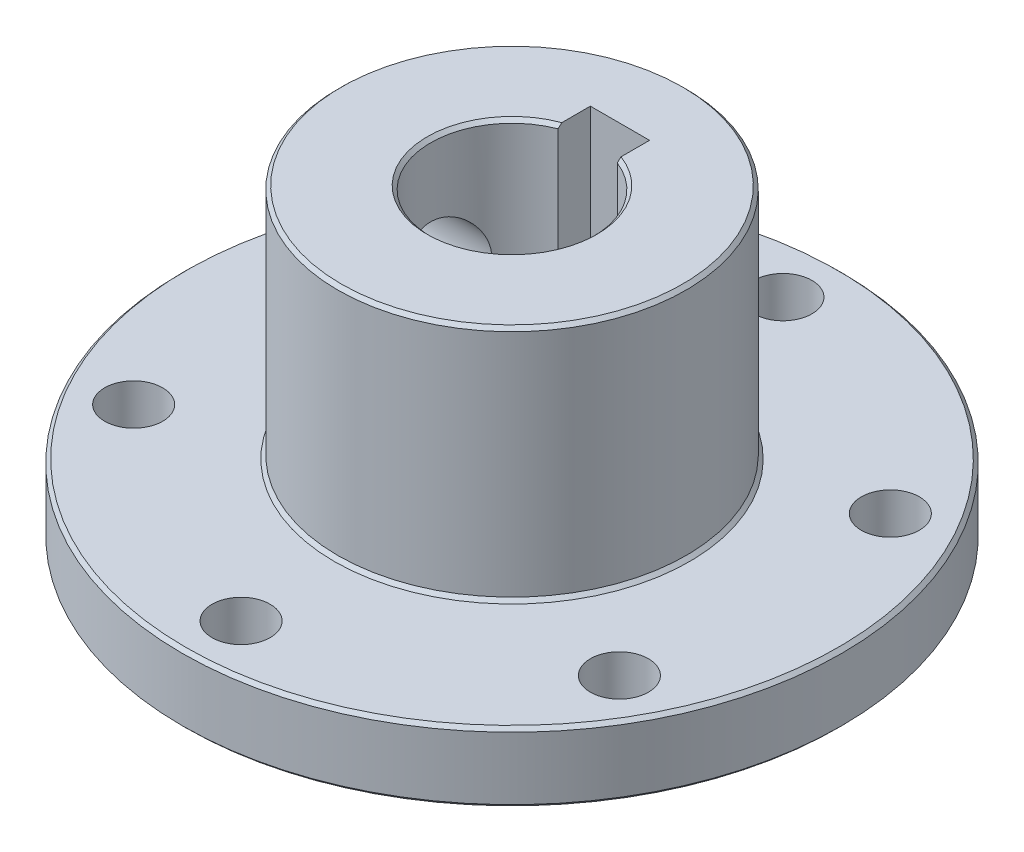
from build123d import *

# Parameters (mm, degrees)
ESQUISSE1_R             = 28.4
ESQUISSE1_R_2           = 7
BOSS_EXTRU_1_DEPTH      = 26.4
ESQUISSE2_OUTSIDE_W     = 75.71
ESQUISSE2_OUTSIDE_H     = 75.71
ESQUISSE2_OUTSIDE_R     = 15
ENL_V_MAT_EXTRU_1_DEPTH = 20.4
ESQUISSE3_R             = 2.5
ENL_V_MAT_EXTRU_2_DEPTH = 27.4
ENL_V_MAT_EXTRU_3_REACH = 30.4
ESQUISSE4_R             = 4
ESQUISSE5_W             = 5.1
ESQUISSE5_H             = 9.3
ENL_V_MAT_EXTRU_4_DEPTH = 27.4000001
CHANFREIN1_SIZE         = 0.3


with BuildPart() as part:
    # Esquisse1 → Boss.-Extru.1 (new body)
    with BuildSketch(Plane(origin=(0, 0, 0), x_dir=(1, 0, 0), z_dir=(0, 1, 0))):
        Circle(ESQUISSE1_R)
        Circle(ESQUISSE1_R_2, mode=Mode.SUBTRACT)
    extrude(amount=BOSS_EXTRU_1_DEPTH)

    # Esquisse2 outside → Enlèv. mat.-Extru.1 (cut)
    with BuildSketch(Plane(origin=(0, 26.4, 0), x_dir=(1, 0, 0), z_dir=(0, 1, 0))):
        Rectangle(ESQUISSE2_OUTSIDE_W, ESQUISSE2_OUTSIDE_H)
        Circle(ESQUISSE2_OUTSIDE_R, mode=Mode.SUBTRACT)
    extrude(amount=-ENL_V_MAT_EXTRU_1_DEPTH, mode=Mode.SUBTRACT)

    # Esquisse3 → Enlèv. mat.-Extru.2 (cut, through all)
    with BuildSketch(Plane.XZ):
        with Locations((0.409323167, 23.746472465)):
            Circle(ESQUISSE3_R)
        with Locations((20.769709989, 11.518751972)):
            Circle(ESQUISSE3_R)
        with Locations((20.360386822, -12.227720494)):
            Circle(ESQUISSE3_R)
        with Locations((-0.409323167, -23.746472465)):
            Circle(ESQUISSE3_R)
        with Locations((-20.769709989, -11.518751972)):
            Circle(ESQUISSE3_R)
        with Locations((-20.360386822, 12.227720494)):
            Circle(ESQUISSE3_R)
    extrude(amount=-ENL_V_MAT_EXTRU_2_DEPTH, mode=Mode.SUBTRACT)

    # Esquisse4 → Enlèv. mat.-Extru.3 (cut, up to next)
    with BuildSketch(Plane(origin=(0, 0, 0), x_dir=(0, 0, -1), z_dir=(1, 0, 0)), mode=Mode.PRIVATE) as enl_v_mat_extru_3_sk1:
        with Locations((0, 16.2)):
            Circle(ESQUISSE4_R)
    enl_v_mat_extru_3_tool1 = extrude(enl_v_mat_extru_3_sk1.sketch, amount=-ENL_V_MAT_EXTRU_3_REACH, mode=Mode.PRIVATE) & part.part
    add(enl_v_mat_extru_3_tool1.solids().sort_by_distance((0, 16.2, 0))[0], mode=Mode.SUBTRACT)

    # Esquisse5 → Enlèv. mat.-Extru.4 (cut, through all)
    with BuildSketch(Plane(origin=(0, 26.4, 0), x_dir=(1, 0, 0), z_dir=(0, 1, 0))):
        with Locations((0, 4.65)):
            Rectangle(ESQUISSE5_W, ESQUISSE5_H)
    extrude(amount=-ENL_V_MAT_EXTRU_4_DEPTH, mode=Mode.SUBTRACT)

    # Chanfrein1
    chanfrein1_edges = [part.edges().sort_by_distance(p)[0] for p in [
        (-15, 6, 0),
        (-15, 26.4, 0),
        (-28.4, 6, 0),
        (-28.4, 0, 0),
        (0, 26.4, 7),
        (0, 0, 7),
    ]]
    chamfer(chanfrein1_edges, length=CHANFREIN1_SIZE)


solid = part.part
